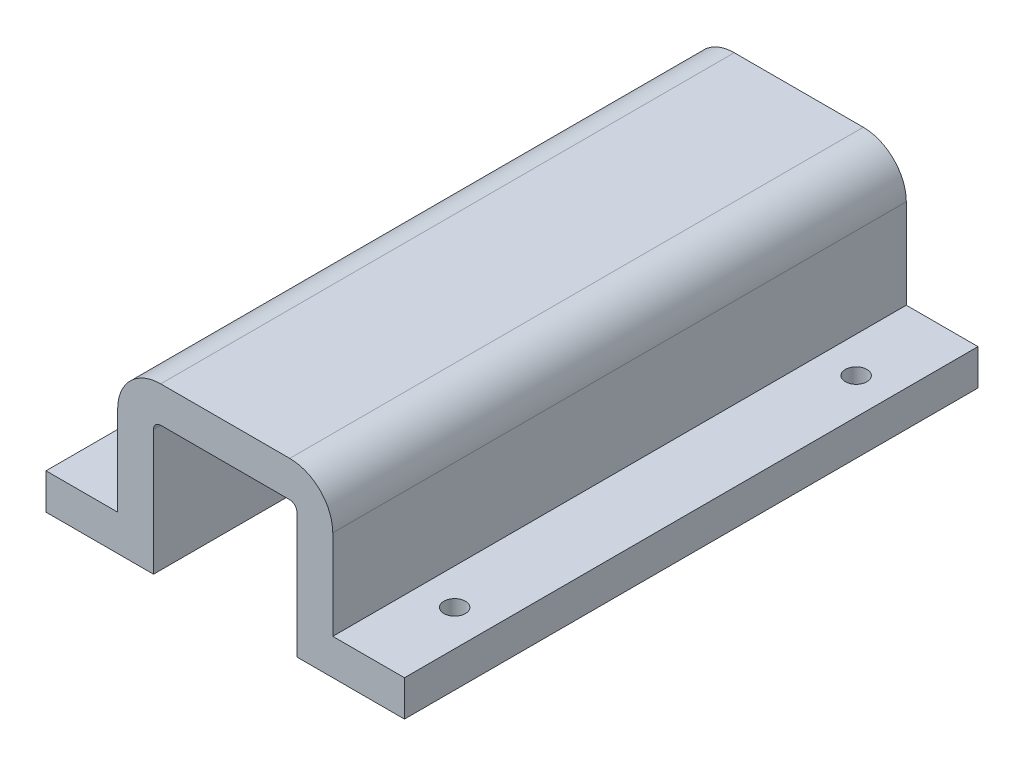
from build123d import *

# Parameters (mm, degrees)
BOSS_EXTRUDE1_DEPTH   = 80
F_3_0MM_DOWEL_HOLE1_D = 3


with BuildPart() as part:
    # Sketch1 → Boss-Extrude1 (new body)
    with BuildSketch(Plane.XY):
        with BuildLine():
            Line((9, 15), (-9, 15))
            ThreePointArc((-9, 15), (-13.242640687, 13.242640687), (-15, 9))
            Line((-15, 9), (-15, -3.5))
            Line((-15, -3.5), (-25, -3.5))
            Line((-25, -3.5), (-25, -8.5))
            Line((-25, -8.5), (-10, -8.5))
            Line((-10, -8.5), (-10, 9))
            ThreePointArc((-10, 9), (-9.707106781, 9.707106781), (-9, 10))
            Line((-9, 10), (9, 10))
            ThreePointArc((9, 10), (9.707106781, 9.707106781), (10, 9))
            Line((10, 9), (10, -8.5))
            Line((10, -8.5), (25, -8.5))
            Line((25, -8.5), (25, -3.5))
            Line((25, -3.5), (15, -3.5))
            Line((15, -3.5), (15, 9))
            ThreePointArc((15, 9), (13.242640687, 13.242640687), (9, 15))
        make_face()
    extrude(amount=BOSS_EXTRUDE1_DEPTH)

    # Ø3.0mm Dowel Hole1 (through all)
    with Locations(Plane(origin=(0, -3.5, 0), x_dir=(1, 0, 0), z_dir=(0, 1, 0))):
        with Locations((-20, -12), (-20, -68), (20, -12), (20, -68)):
            Hole(F_3_0MM_DOWEL_HOLE1_D / 2)


solid = part.part
